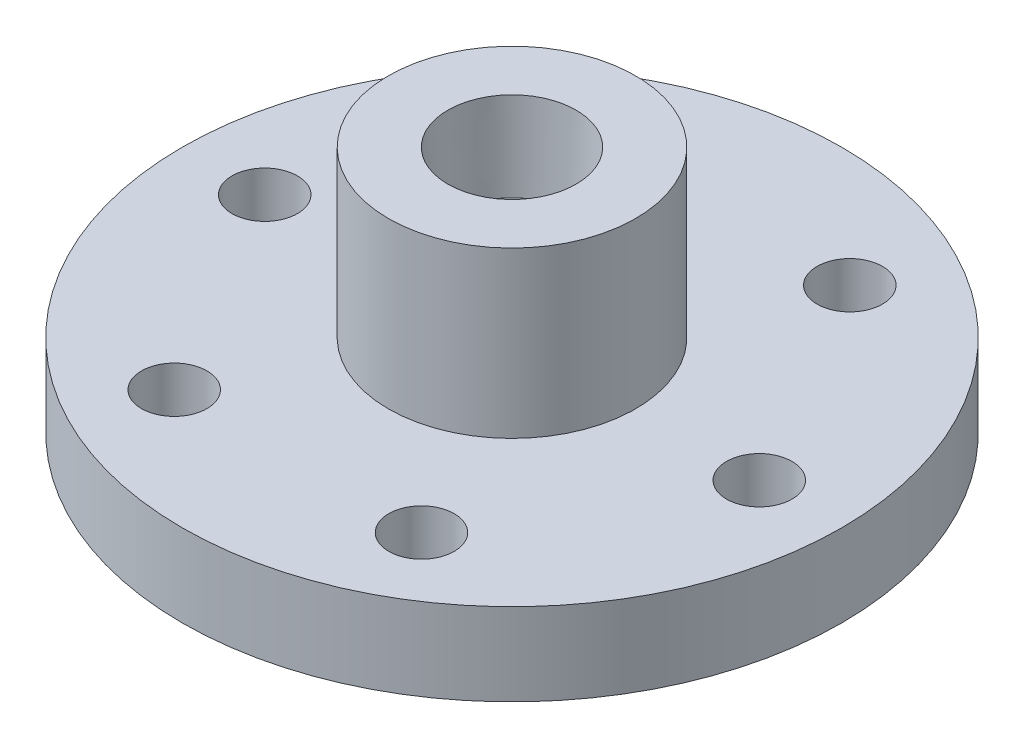
from build123d import *

# Parameters (mm, degrees)
F_3_8_0_375_DIAMETER_HOLE1_D = 9.525
F_3_8_CLEARANCE_HOLE1_D      = 10.0838
CIRPATTERN1_COUNT            = 6


with BuildPart() as part:
    # Sketch1 → Revolve1 (revolve)
    with BuildSketch(Plane.XY):
        Polygon((-12.827, 0), (-50.8, 0), (-50.8, 12.7), (-19.05, 12.7), (-19.05, 38.1), (0, 38.1), (0, 0), (-9.525, 0), (-9.525, 2.54), (-12.827, 2.54), align=None)
    revolve(axis=Axis((0, 38.1, 0), (0, -1, 0)))

    # 3/8 (0.375) Diameter Hole1 (through all)
    with Locations(Plane(origin=(0, 38.1, 0), x_dir=(1, 0, 0), z_dir=(0, 1, 0))):
        with Locations((0, 0)):
            Hole(F_3_8_0_375_DIAMETER_HOLE1_D / 2)

    # Sketch3 → 1/2 NPT Tapped Hole1 (revolve, cut)
    with BuildSketch(Plane(origin=(0, 38.1, 0), x_dir=(0, 0, 1), z_dir=(1, 0, 0))):
        Polygon((0, 0), (0, 27.970543693), (8.9281, 22.606), (8.9281, 13.462), (9.479726792, 13.462), (9.8827971, 0), align=None)
    revolve(axis=Axis((0, 44.45, 0), (0, -1, 0)), mode=Mode.SUBTRACT)

    # 3/8 Clearance Hole1 (through all)
    with Locations(Plane(origin=(0, 12.7, 0), x_dir=(1, 0, 0), z_dir=(0, 1, 0))):
        with Locations((38.1, 0)):
            f_3_8_clearance_hole1 = Hole(F_3_8_CLEARANCE_HOLE1_D / 2)

    # CirPattern1: 3/8 Clearance Hole1 ×6 about axis
    cirpattern1_axis = Axis((0, 0, 0), (0, 1, 0))
    for i in range(1, CIRPATTERN1_COUNT):
        add(f_3_8_clearance_hole1.rotate(cirpattern1_axis, i * 360 / CIRPATTERN1_COUNT), mode=Mode.SUBTRACT)


solid = part.part
